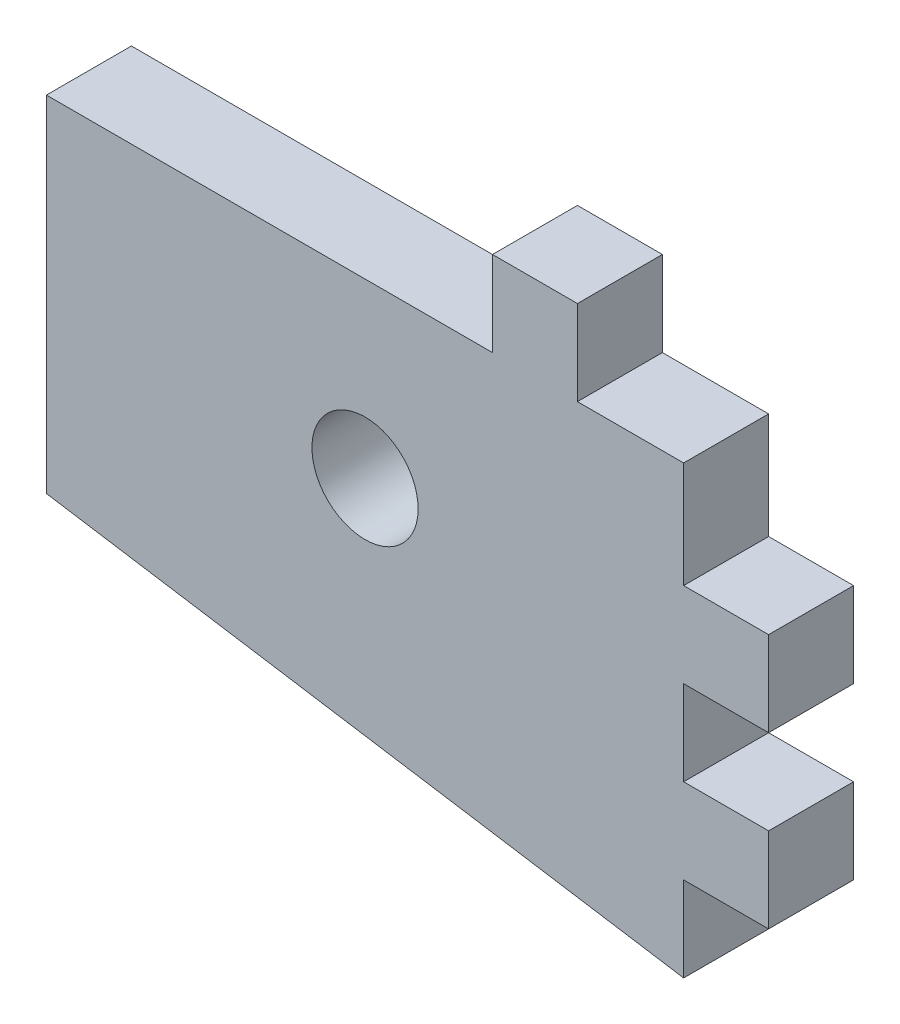
from build123d import *

# Parameters (mm, degrees)
SKETCH1_R           = 2.5
BOSS_EXTRUDE1_DEPTH = 4
SKETCH2_W           = 4
SKETCH2_H           = 4
BOSS_EXTRUDE2_DEPTH = 4


with BuildPart() as part:
    # Sketch1 → Boss-Extrude1 (new body)
    with BuildSketch(Plane.XY):
        Polygon((0, 9.539473684), (0, -11.460526316), (-30, -6.708993106), (-30, 9.539473684), align=None)
        with Locations((-15, 1.415240289)):
            Circle(SKETCH1_R, mode=Mode.SUBTRACT)
    extrude(amount=BOSS_EXTRUDE1_DEPTH)

    # Sketch2 → Boss-Extrude2 (add)
    with BuildSketch(Plane.XY.offset(4)):
        with Locations((2, 2.539473684)):
            Rectangle(SKETCH2_W, SKETCH2_H)
        with Locations((-7, 11.539473684)):
            Rectangle(SKETCH2_W, SKETCH2_H)
        with Locations((2, -5.460526316)):
            Rectangle(SKETCH2_W, SKETCH2_H)
    extrude(amount=-BOSS_EXTRUDE2_DEPTH)


solid = part.part
